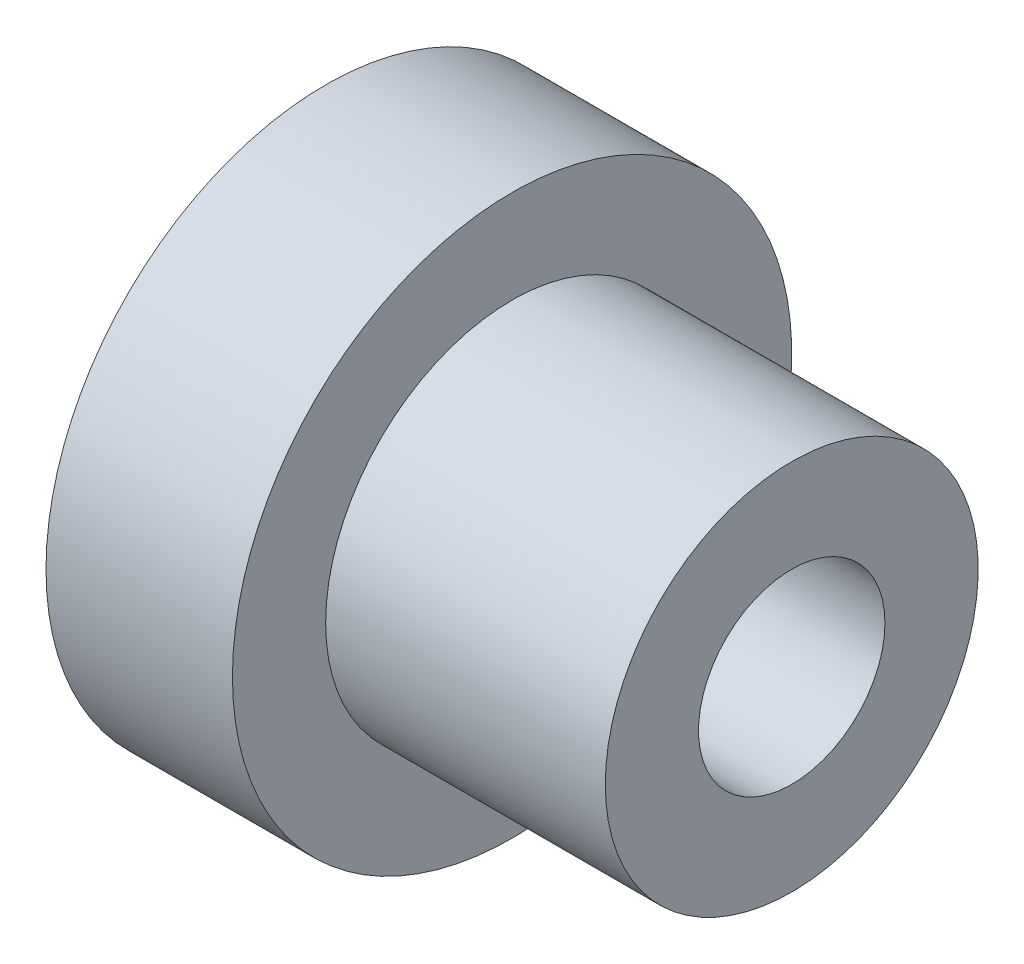
from build123d import *

# Parameters (mm, degrees)
ESQUISSE4_R             = 1.5
ENL_V_MAT_EXTRU_1_DEPTH = 8.5


with BuildPart() as part:
    # Esquisse3 → Révolution1 (revolve)
    with BuildSketch(Plane.XY):
        Polygon((0, 0), (0, 4.5), (3, 4.5), (3, 3), (7.5, 3), (7.5, 0), align=None)
    revolve(axis=Axis((-5.516579947, 0, 0), (1, 0, 0)))

    # Esquisse4 → Enlèv. mat.-Extru.1 (cut, through all)
    with BuildSketch(Plane(origin=(7.5, 0, 0), x_dir=(0, 0, -1), z_dir=(1, 0, 0))):
        Circle(ESQUISSE4_R)
    extrude(amount=-ENL_V_MAT_EXTRU_1_DEPTH, mode=Mode.SUBTRACT)


solid = part.part
